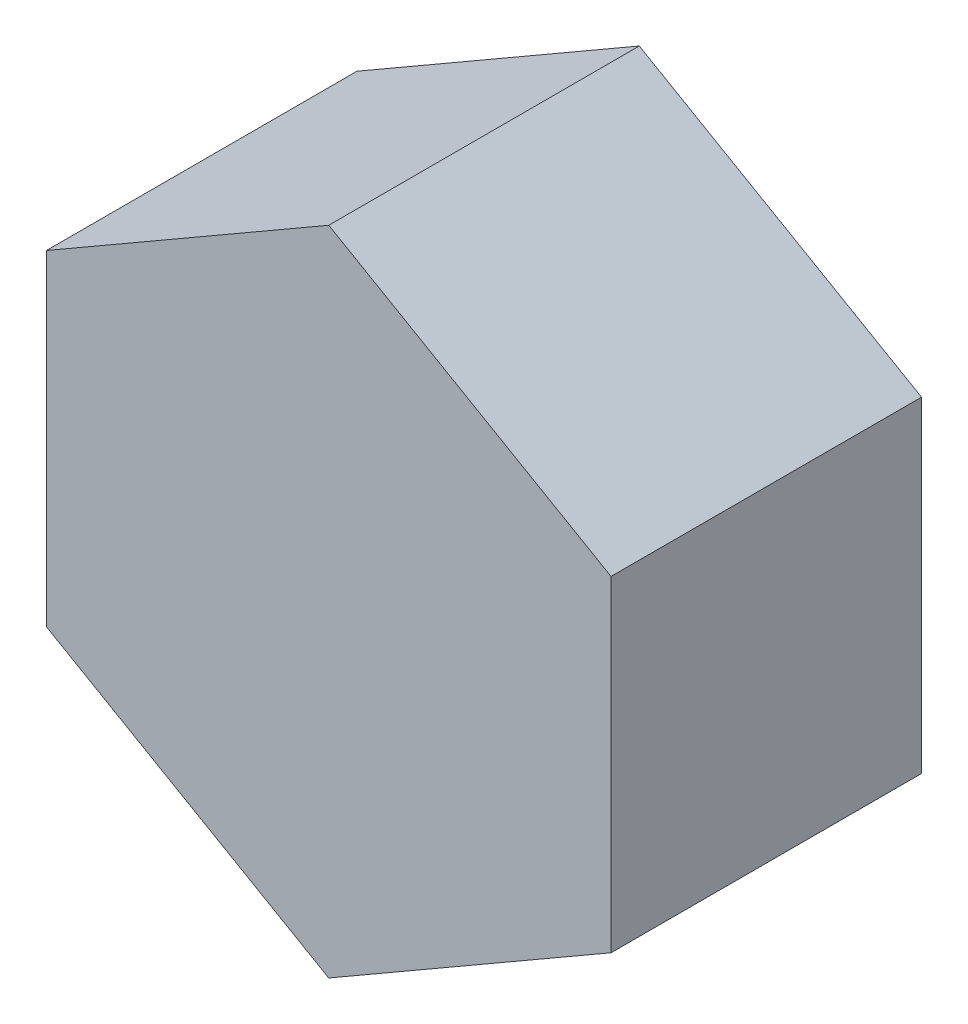
from build123d import *

# Parameters (mm, degrees)
BOSS_EXTRUDE1_DEPTH = 13.97


with BuildPart() as part:
    # Sketch1 → Boss-Extrude1 (new body)
    with BuildSketch(Plane.XY):
        Polygon((0, 14.664696837), (-12.7, 7.332348419), (-12.7, -7.332348419), (0, -14.664696837), (12.7, -7.332348419), (12.7, 7.332348419), align=None)
    extrude(amount=BOSS_EXTRUDE1_DEPTH)

    # Sketch4 → Cut-Revolve1 (revolve, cut)
    with BuildSketch(Plane(origin=(0, 0, 0), x_dir=(0, 0, -1), z_dir=(1, 0, 0))):
        with BuildLine():
            Line((0, 5.479886784), (0, 10.067284703))
            Line((0, 10.067284703), (2.770121515, 10.067284703))
            Line((2.770121515, 10.067284703), (2.770121515, 0))
            Line((2.770121515, 0), (-9.929878485, 0))
            ThreePointArc((-9.929878485, 0), (-6.647991818, 5.559602556), (-0.1947035, 5.372438024))
            ThreePointArc((-0.1947035, 5.372438024), (-0.065637733, 5.368694733), (0, 5.479886784))
        make_face()
    revolve(axis=Axis((0, 0, 9.929878485), (0, 0, -1)), mode=Mode.SUBTRACT)


solid = part.part
